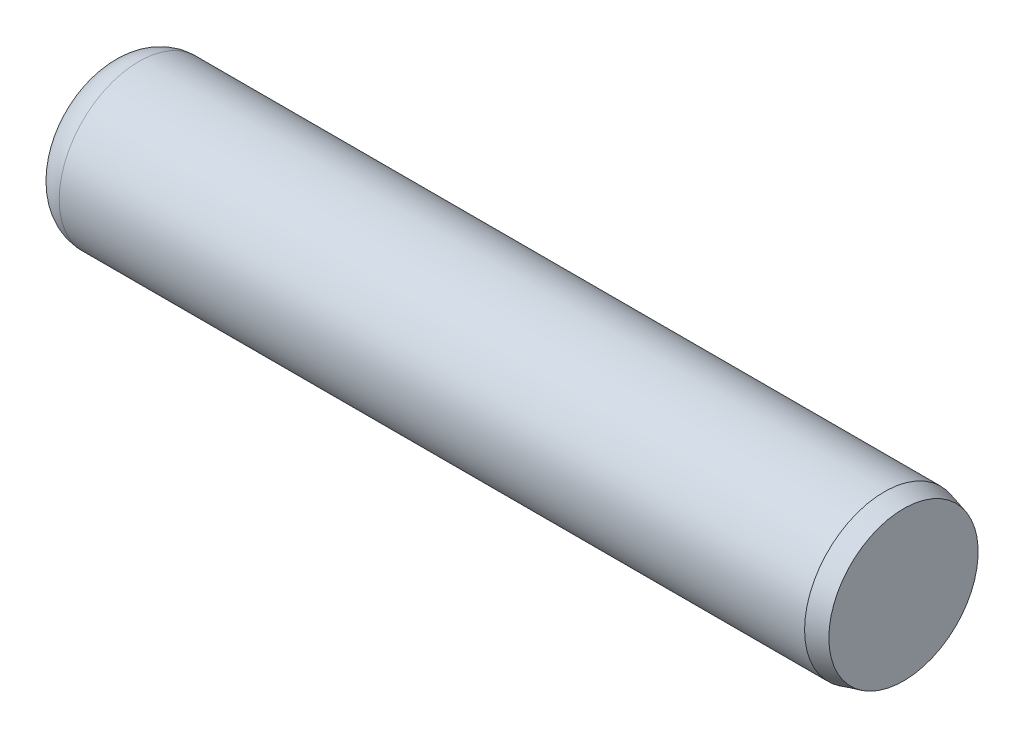
from build123d import *


with BuildPart() as part:
    # Sketch1 → Base-Revolve (revolve)
    with BuildSketch(Plane.XY, mode=Mode.PRIVATE) as base_revolve_sk:
        with BuildLine():
            Line((0, 0), (15.875, 0))
            Line((15.875, 0), (15.875, 1.487788016))
            Line((15.875, 1.487788016), (15.4933904, 1.59004))
            Line((15.4933904, 1.59004), (0.636016, 1.59004))
            ThreePointArc((0.636016, 1.59004), (0.186284773, 1.403755227), (0, 0.954024))
            Line((0, 0.954024), (0, 0))
        make_face()
    revolve(base_revolve_sk.sketch.rotate(Axis((-6.35, 0, 0), (1, 0, 0)), 90), axis=Axis((-6.35, 0, 0), (1, 0, 0)))  # turned: the seam where the file's is


solid = part.part
